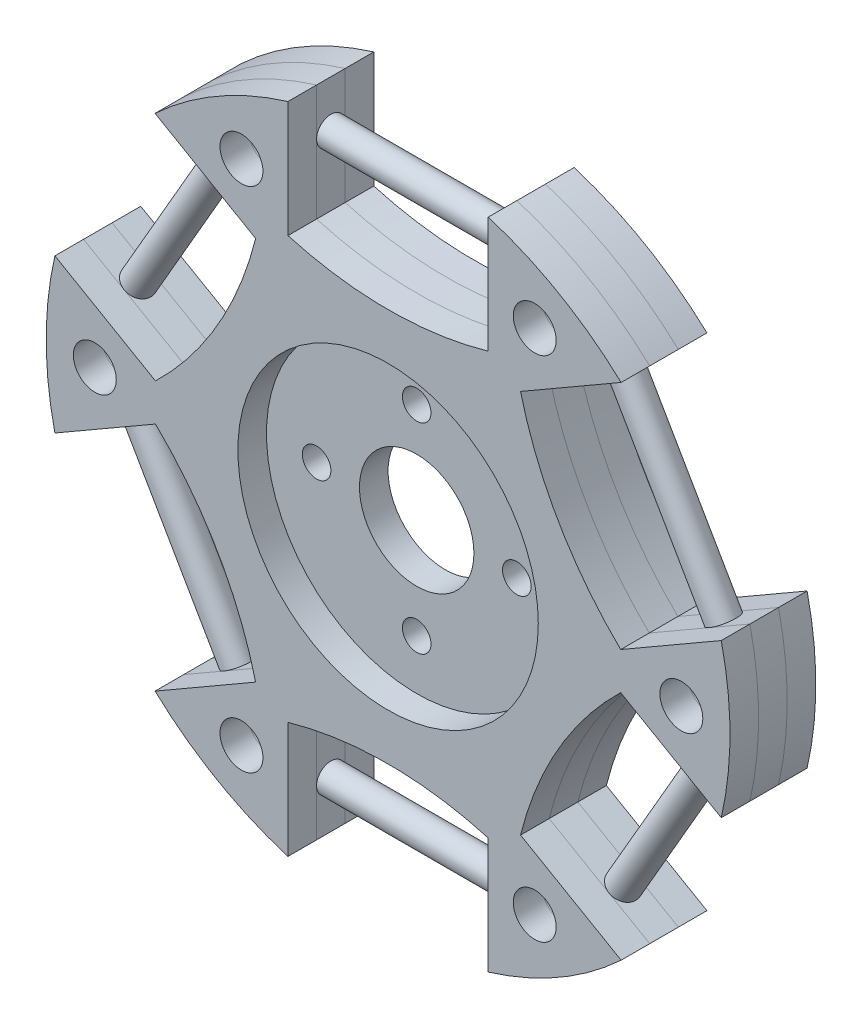
from build123d import *

# Parameters (mm, degrees)
SKETCH_1_R               = 25.4
SKETCH_1_R_2             = 10.5
EXTRUDE_1_DEPTH          = 2
SKETCH_2_R               = 25.4
SKETCH_2_R_2             = 4
EXTRUDE_2_DEPTH          = 2
SKETCH_3_R               = 25.4
SKETCH_3_R_2             = 10.5
EXTRUDE_3_DEPTH          = 2
CUT_EXTRUDE_1_DEPTH      = 20.5
SKETCH_5_R               = 1.5
CUT_EXTRUDE_2_DEPTH      = 20.5
SKETCH_6_R               = 1
EXTRUDE_4_DEPTH          = 14
PATTERN_CIRCULAR_1_COUNT = 6
SKETCH_7_R               = 1
CUT_EXTRUDE_3_DEPTH      = 14
SKETCH_8_R               = 33.9
SKETCH_8_R_2             = 23.9
CUT_EXTRUDE_1_2_DEPTH    = 10


with BuildPart() as part:
    # 草图1 → 凸台-拉伸1 (new body)
    with BuildSketch(Plane.XY):
        Circle(SKETCH_1_R)
        Circle(SKETCH_1_R_2, mode=Mode.SUBTRACT)
    extrude(amount=EXTRUDE_1_DEPTH)


with BuildPart() as body_2:
    # 草图2 → 凸台-拉伸2 (new body)
    with BuildSketch(Plane.XY.offset(2)):
        Circle(SKETCH_2_R)
        Circle(SKETCH_2_R_2, mode=Mode.SUBTRACT)
    extrude(amount=EXTRUDE_2_DEPTH)


with BuildPart() as body_3:
    # 草图3 → 凸台-拉伸3 (new body)
    with BuildSketch(Plane.XY.offset(4)):
        Circle(SKETCH_3_R)
        Circle(SKETCH_3_R_2, mode=Mode.SUBTRACT)
    extrude(amount=EXTRUDE_3_DEPTH)


with BuildPart() as cut_extrude_1_tool:
    # 草图4 → Cut-Extrude 1 (new body)
    with BuildSketch(Plane.XY.offset(6)):
        with BuildLine():
            Line((9.259682334, 13.428983857), (17.645212224, 18.270371796))
            ThreePointArc((17.645212224, 18.270371796), (21.997045256, 12.7), (24.645212224, 6.146016143))
            Line((24.645212224, 6.146016143), (16.259682334, 1.304628204))
            ThreePointArc((16.259682334, 1.304628204), (11.907849302, 6.875), (9.259682334, 13.428983857))
        make_face()
        with BuildLine():
            Line((7, 14.733612061), (7, 24.416387939))
            ThreePointArc((7, 24.416387939), (0, 25.4), (-7, 24.416387939))
            Line((-7, 24.416387939), (-7, 14.733612061))
            ThreePointArc((-7, 14.733612061), (0, 13.75), (7, 14.733612061))
        make_face()
        with BuildLine():
            Line((16.259682334, -1.304628204), (24.645212224, -6.146016143))
            ThreePointArc((24.645212224, -6.146016143), (21.997045256, -12.7), (17.645212224, -18.270371796))
            Line((17.645212224, -18.270371796), (9.259682334, -13.428983857))
            ThreePointArc((9.259682334, -13.428983857), (11.907849302, -6.875), (16.259682334, -1.304628204))
        make_face()
        with BuildLine():
            Line((7, -14.733612061), (7, -24.416387939))
            ThreePointArc((7, -24.416387939), (0, -25.4), (-7, -24.416387939))
            Line((-7, -24.416387939), (-7, -14.733612061))
            ThreePointArc((-7, -14.733612061), (0, -13.75), (7, -14.733612061))
        make_face()
        with BuildLine():
            Line((-9.259682334, -13.428983857), (-17.645212224, -18.270371796))
            ThreePointArc((-17.645212224, -18.270371796), (-21.997045256, -12.7), (-24.645212224, -6.146016143))
            Line((-24.645212224, -6.146016143), (-16.259682334, -1.304628204))
            ThreePointArc((-16.259682334, -1.304628204), (-11.907849302, -6.875), (-9.259682334, -13.428983857))
        make_face()
        with BuildLine():
            Line((-16.259682334, 1.304628204), (-24.645212224, 6.146016143))
            ThreePointArc((-24.645212224, 6.146016143), (-21.997045256, 12.7), (-17.645212224, 18.270371796))
            Line((-17.645212224, 18.270371796), (-9.259682334, 13.428983857))
            ThreePointArc((-9.259682334, 13.428983857), (-11.907849302, 6.875), (-16.259682334, 1.304628204))
        make_face()
    extrude(amount=-CUT_EXTRUDE_1_DEPTH)


with BuildPart() as part_1:
    add(part.part)

    # Cut-Extrude 1: cut by cut_extrude_1_tool
    add(cut_extrude_1_tool.part, mode=Mode.SUBTRACT)


with BuildPart() as body_2_1:
    add(body_2.part)

    # Cut-Extrude 1: cut by cut_extrude_1_tool
    add(cut_extrude_1_tool.part, mode=Mode.SUBTRACT)


with BuildPart() as body_3_1:
    add(body_3.part)

    # Cut-Extrude 1: cut by cut_extrude_1_tool
    add(cut_extrude_1_tool.part, mode=Mode.SUBTRACT)


with BuildPart() as cut_extrude_2_tool:
    # 草图5 → 切除-拉伸2 (new body)
    with BuildSketch(Plane.XY.offset(6)):
        with Locations((10.25, 17.753520778)):
            Circle(SKETCH_5_R)
        with Locations((20.5, 0)):
            Circle(SKETCH_5_R)
        with Locations((10.25, -17.753520778)):
            Circle(SKETCH_5_R)
        with Locations((-10.25, -17.753520778)):
            Circle(SKETCH_5_R)
        with Locations((-20.5, 0)):
            Circle(SKETCH_5_R)
        with Locations((-10.25, 17.753520778)):
            Circle(SKETCH_5_R)
    extrude(amount=-CUT_EXTRUDE_2_DEPTH)


with BuildPart() as part_2:
    add(part_1.part)

    # 切除-拉伸2: cut by cut_extrude_2_tool
    add(cut_extrude_2_tool.part, mode=Mode.SUBTRACT)


with BuildPart() as body_2_2:
    add(body_2_1.part)

    # 切除-拉伸2: cut by cut_extrude_2_tool
    add(cut_extrude_2_tool.part, mode=Mode.SUBTRACT)

    # 草图6 → 凸台-拉伸4 (add)
    with BuildSketch(Plane(origin=(-7, 0, 0), x_dir=(0, 0, -1), z_dir=(1, 0, 0))):
        with Locations((-3, 19.575)):
            Circle(SKETCH_6_R)
    extrude_4 = extrude(amount=EXTRUDE_4_DEPTH)

    # 阵列(圆周)1: 凸台-拉伸4 ×6 about axis
    pattern_circular_1_axis = Axis((0, 0, 6), (0, 0, 1))
    for i in range(1, PATTERN_CIRCULAR_1_COUNT):
        add(extrude_4.rotate(pattern_circular_1_axis, i * 360 / PATTERN_CIRCULAR_1_COUNT))

    # 草图7 → 切除-拉伸3 (cut)
    with BuildSketch(Plane.XY.offset(4)):
        with Locations((0, 7)):
            Circle(SKETCH_7_R)
        with Locations((7, 0)):
            Circle(SKETCH_7_R)
        with Locations((0, -7)):
            Circle(SKETCH_7_R)
        with Locations((-7, 0)):
            Circle(SKETCH_7_R)
    extrude(amount=-CUT_EXTRUDE_3_DEPTH, mode=Mode.SUBTRACT)


with BuildPart() as body_3_2:
    add(body_3_1.part)

    # 切除-拉伸2: cut by cut_extrude_2_tool
    add(cut_extrude_2_tool.part, mode=Mode.SUBTRACT)


with BuildPart() as cut_extrude_1_2_tool:
    # 草图8 → Cut-Extrude 1 2 (new body)
    with BuildSketch(Plane.XY.offset(6)):
        Circle(SKETCH_8_R)
        Circle(SKETCH_8_R_2, mode=Mode.SUBTRACT)
    extrude(amount=-CUT_EXTRUDE_1_2_DEPTH)


with BuildPart() as part_3:
    add(part_2.part)

    # Cut-Extrude 1 2: cut by cut_extrude_1_2_tool
    add(cut_extrude_1_2_tool.part, mode=Mode.SUBTRACT)


with BuildPart() as body_2_3:
    add(body_2_2.part)

    # Cut-Extrude 1 2: cut by cut_extrude_1_2_tool
    add(cut_extrude_1_2_tool.part, mode=Mode.SUBTRACT)


with BuildPart() as body_3_3:
    add(body_3_2.part)

    # Cut-Extrude 1 2: cut by cut_extrude_1_2_tool
    add(cut_extrude_1_2_tool.part, mode=Mode.SUBTRACT)


solid = Compound([part_3.part, body_2_3.part, body_3_3.part])
